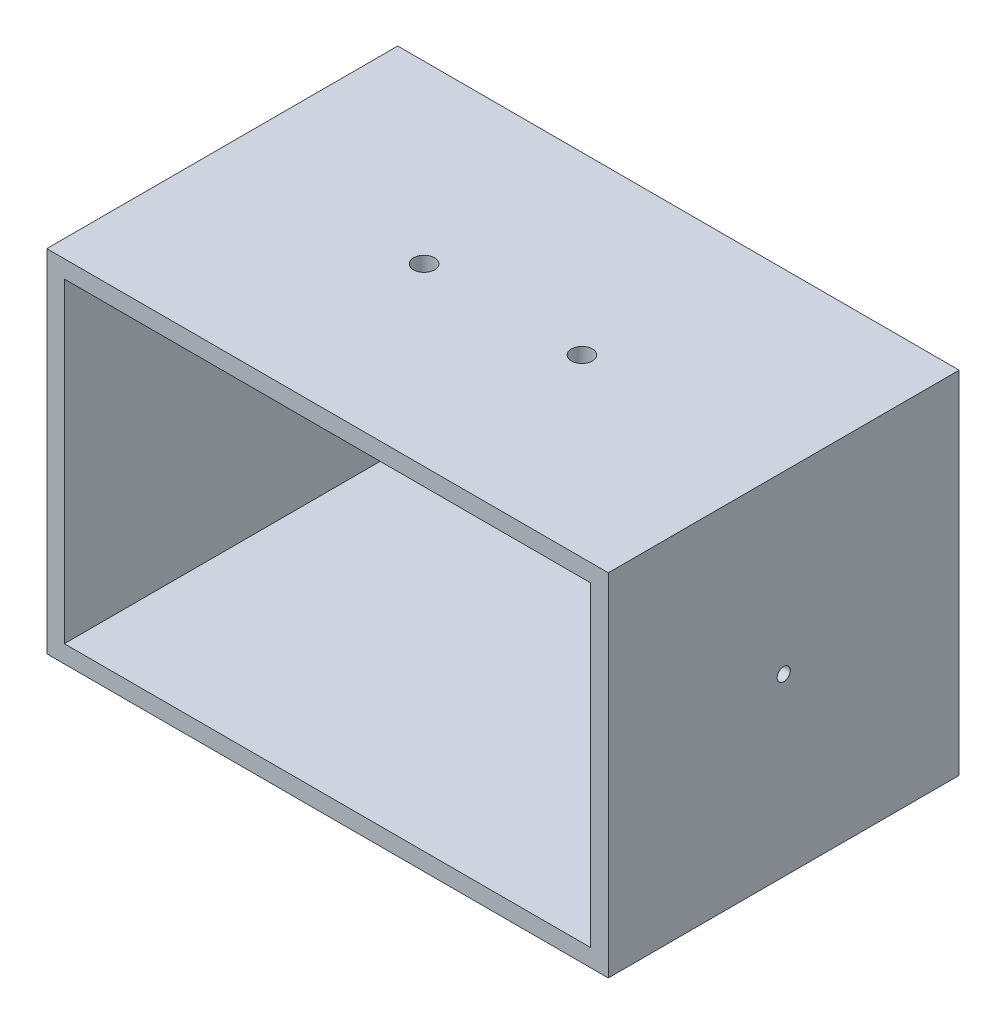
from build123d import *

# Parameters (mm, degrees)
SKETCH1_W           = 203.2
SKETCH1_H           = 127
BOSS_EXTRUDE1_DEPTH = 127
SHELL1_T            = -6.35
SKETCH2_R           = 2.38125
CUT_EXTRUDE1_DEPTH  = 204.2
SKETCH4_R           = 3.794312019
CUT_EXTRUDE3_DEPTH  = 23.368


with BuildPart() as part:
    # Sketch1 → Boss-Extrude1 (new body)
    with BuildSketch(Plane(origin=(0, 0, 0), x_dir=(1, 0, 0), z_dir=(0, 1, 0))):
        with Locations((101.6, 63.5)):
            Rectangle(SKETCH1_W, SKETCH1_H)
    extrude(amount=BOSS_EXTRUDE1_DEPTH)

    # Shell1
    shell1_openings = [part.faces().sort_by_distance(p)[0] for p in [
        (101.6, 63.5, 0),
    ]]
    offset(amount=SHELL1_T, openings=shell1_openings, kind=Kind.INTERSECTION)

    # Sketch2 → Cut-Extrude1 (cut, through all)
    with BuildSketch(Plane(origin=(203.2, 0, 0), x_dir=(0, 0, -1), z_dir=(1, 0, 0))):
        with Locations((63.5, 63.5)):
            Circle(SKETCH2_R)
    extrude(amount=-CUT_EXTRUDE1_DEPTH, mode=Mode.SUBTRACT)

    # Sketch4 → Cut-Extrude3 (cut)
    with BuildSketch(Plane(origin=(0, 127, 0), x_dir=(1, 0, 0), z_dir=(0, 1, 0))):
        with Locations((73.037262301, 63.5)):
            Circle(SKETCH4_R)
        with Locations((130.162737699, 63.5)):
            Circle(SKETCH4_R)
    extrude(amount=-CUT_EXTRUDE3_DEPTH, mode=Mode.SUBTRACT)


solid = part.part
